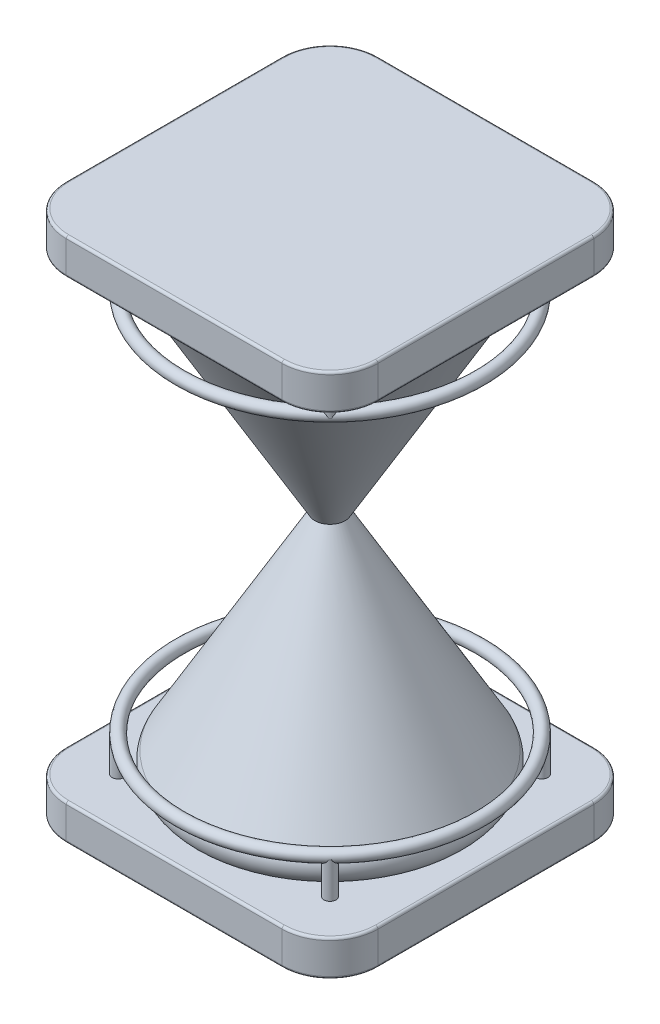
from build123d import *

# Parameters (mm, degrees)
SKETCH2_W             = 330.2
SKETCH2_H             = 330.2
BOSS_EXTRUDE1_DEPTH   = 38.1
FILLET1_R             = 50.8
FILLET2_R             = 2.54
SKETCH3_R             = 6.35
BOSS_EXTRUDE2_DEPTH   = 38.1
BOSS_EXTRUDE2_2_DEPTH = 38.1
BOSS_EXTRUDE2_3_DEPTH = 38.1
BOSS_EXTRUDE2_4_DEPTH = 38.1
SWEEP1_PROFILE_R      = 6.35


with BuildPart() as part:
    # Sketch1 → Revolve-Thin1 (revolve)
    with BuildSketch(Plane.XY):
        with BuildLine():
            Line((0, 0), (127, 0))
            ThreePointArc((127, 0), (137.998522628, 6.35), (137.998522628, 19.05))
            Line((137.998522628, 19.05), (10.16, 240.472816356))
            Line((10.16, 240.472816356), (14.559409051, 243.012816356))
            Line((14.559409051, 243.012816356), (142.397931679, 21.59))
            ThreePointArc((142.397931679, 21.59), (142.397931679, 3.81), (127, -5.08))
            Line((127, -5.08), (0, -5.08))
            Line((0, -5.08), (0, 0))
        make_face()
    revolve(axis=Axis((0, 374.282249101, 0), (0, -1, 0)))


with BuildPart() as body_2:
    # Sketch2 → Boss-Extrude1 (new body)
    with BuildSketch(Plane(origin=(0, 0, 0), x_dir=(1, 0, 0), z_dir=(0, 1, 0))):
        Rectangle(SKETCH2_W, SKETCH2_H)
    extrude(amount=-BOSS_EXTRUDE1_DEPTH)

    # Fillet1
    fillet1_edges = [body_2.edges().sort_by_distance(p)[0] for p in [
        (-165.1, -19.05, -165.1),
        (165.1, -19.05, -165.1),
        (165.1, -19.05, 165.1),
        (-165.1, -19.05, 165.1),
    ]]
    fillet(fillet1_edges, radius=FILLET1_R)

    # Fillet2
    fillet2_edges = [body_2.edges().sort_by_distance(p)[0] for p in [
        (0, 0, 165.1),
        (0, -38.1, 165.1),
        (-165.1, 0, 0),
        (165.1, 0, 0),
        (0, 0, -165.1),
        (-150.221024484, 0, 150.221024484),
        (-150.221024484, 0, -150.221024484),
        (150.221024484, 0, -150.221024484),
        (150.221024484, 0, 150.221024484),
        (165.1, -38.1, 0),
        (-165.1, -38.1, 0),
        (0, -38.1, -165.1),
        (-150.221024484, -38.1, 150.221024484),
        (-150.221024484, -38.1, -150.221024484),
        (150.221024484, -38.1, -150.221024484),
        (150.221024484, -38.1, 150.221024484),
    ]]
    fillet(fillet2_edges, radius=FILLET2_R)


with BuildPart() as body_3:
    # Sketch3 → Boss-Extrude2 (new body)
    with BuildSketch(Plane(origin=(0, 0, 0), x_dir=(1, 0, 0), z_dir=(0, 1, 0))):
        with Locations((-112.253201513, 112.253201513)):
            Circle(SKETCH3_R)
    extrude(amount=BOSS_EXTRUDE2_DEPTH)


with BuildPart() as body_4:
    # Sketch3 → Boss-Extrude2 2 (new body)
    with BuildSketch(Plane(origin=(0, 0, 0), x_dir=(1, 0, 0), z_dir=(0, 1, 0))):
        with Locations((112.253201513, 112.253201513)):
            Circle(SKETCH3_R)
    extrude(amount=BOSS_EXTRUDE2_2_DEPTH)


with BuildPart() as body_5:
    # Sketch3 → Boss-Extrude2 3 (new body)
    with BuildSketch(Plane(origin=(0, 0, 0), x_dir=(1, 0, 0), z_dir=(0, 1, 0))):
        with Locations((112.253201513, -112.253201513)):
            Circle(SKETCH3_R)
    extrude(amount=BOSS_EXTRUDE2_3_DEPTH)


with BuildPart() as body_6:
    # Sketch3 → Boss-Extrude2 4 (new body)
    with BuildSketch(Plane(origin=(0, 0, 0), x_dir=(1, 0, 0), z_dir=(0, 1, 0))):
        with Locations((-112.253201513, -112.253201513)):
            Circle(SKETCH3_R)
    extrude(amount=BOSS_EXTRUDE2_4_DEPTH)


with BuildPart() as body_7:
    # Sweep1: sweep along a path in Sketch4
    with BuildLine(Plane(origin=(0, 38.1, 0), x_dir=(1, 0, 0), z_dir=(0, 1, 0))) as sweep1_path:
        CenterArc((0, 0), 158.75, 0, 360)
    # Sweep1 profile (on start of the path) → Sweep1 (sweep)
    with BuildSketch(Plane(origin=(158.75, 38.1, 0), x_dir=(-1, 0, 0), z_dir=(0, 0, -1))):
        Circle(SWEEP1_PROFILE_R)
    sweep(path=sweep1_path.line)


with BuildPart() as body_8:
    # Mirror2: mirrored copy
    add(body_2.part.mirror(Plane(origin=(0, 240.472816356, 0), x_dir=(0, 0, 1), z_dir=(0, -1, 0))))


with BuildPart() as body_9:
    # Mirror2 2: mirrored copy
    add(part.part.mirror(Plane(origin=(0, 240.472816356, 0), x_dir=(0, 0, 1), z_dir=(0, -1, 0))))


with BuildPart() as body_10:
    # Mirror2 3: mirrored copy
    add(body_7.part.mirror(Plane(origin=(0, 240.472816356, 0), x_dir=(0, 0, 1), z_dir=(0, -1, 0))))


with BuildPart() as body_11:
    # Mirror2 4: mirrored copy
    add(body_3.part.mirror(Plane(origin=(0, 240.472816356, 0), x_dir=(0, 0, 1), z_dir=(0, -1, 0))))


with BuildPart() as body_12:
    # Mirror2 5: mirrored copy
    add(body_6.part.mirror(Plane(origin=(0, 240.472816356, 0), x_dir=(0, 0, 1), z_dir=(0, -1, 0))))


with BuildPart() as body_13:
    # Mirror2 6: mirrored copy
    add(body_5.part.mirror(Plane(origin=(0, 240.472816356, 0), x_dir=(0, 0, 1), z_dir=(0, -1, 0))))


with BuildPart() as body_14:
    # Mirror2 7: mirrored copy
    add(body_4.part.mirror(Plane(origin=(0, 240.472816356, 0), x_dir=(0, 0, 1), z_dir=(0, -1, 0))))


solid = Compound([part.part, body_2.part, body_3.part, body_4.part, body_5.part, body_6.part, body_7.part, body_8.part, body_9.part, body_10.part, body_11.part, body_12.part, body_13.part, body_14.part])
